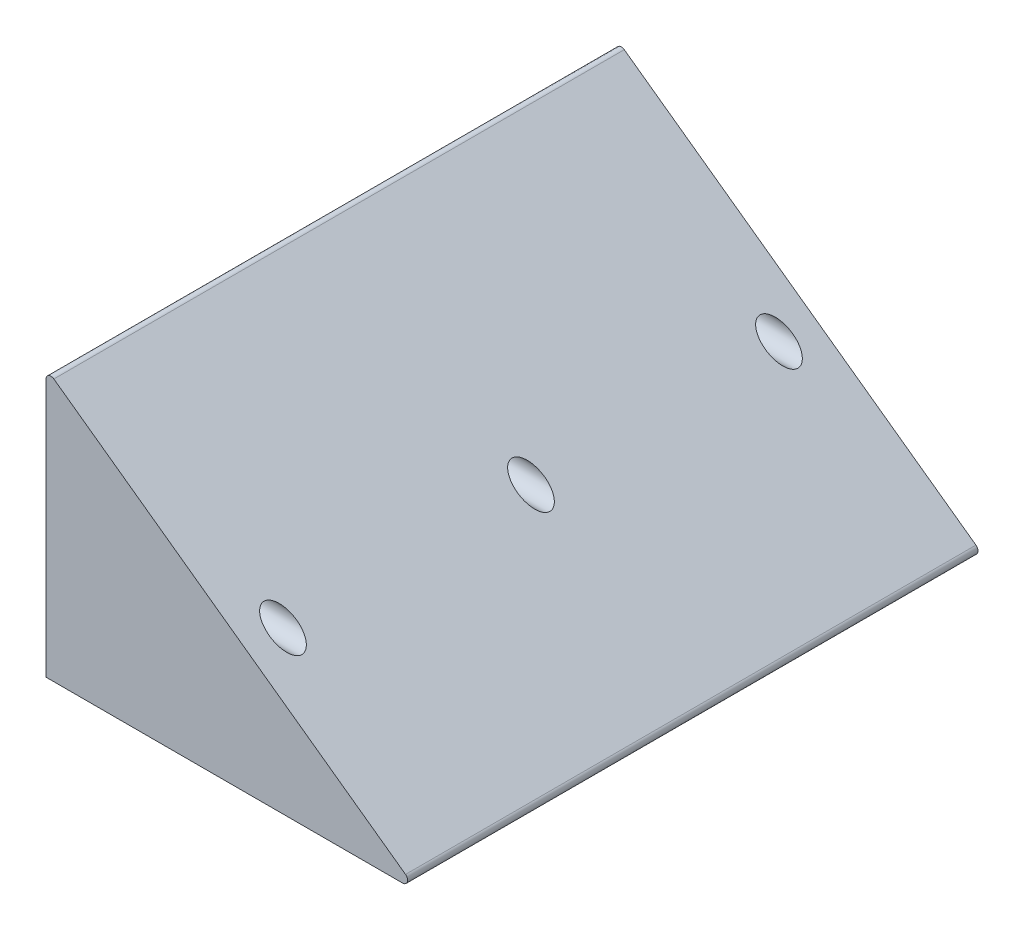
from build123d import *

# Parameters (mm, degrees)
AUFSATZ_LINEAR_AUSTRAGEN1_DEPTH                      = 230
STIRNSENKUNG_F_R_M6_ZYLINDERSCHRAUBE_MIT_D           = 6.6
STIRNSENKUNG_F_R_M6_ZYLINDERSCHRAUBE_MIT_CBORE_D     = 11
STIRNSENKUNG_F_R_M6_ZYLINDERSCHRAUBE_MIT_CBORE_DEPTH = 106.4


with BuildPart() as part:
    # Skizze1 → Aufsatz-Linear austragen1 (new body)
    with BuildSketch(Plane.XY):
        with BuildLine():
            Line((0, 104.095532512), (0, 0))
            Line((0, 0), (143.799350711, 0))
            ThreePointArc((143.799350711, 0), (145.702786731, 1.386052676), (144.967960163, 3.623068683))
            Line((144.967960163, 3.623068683), (3.168609452, 105.718601195))
            ThreePointArc((3.168609452, 105.718601195), (1.088193799, 105.875591346), (0, 104.095532512))
        make_face()
    extrude(amount=-AUFSATZ_LINEAR_AUSTRAGEN1_DEPTH)

    # Stirnsenkung für M6 Zylinderschraube mit Innensechskant1 (through all)
    with Locations(Plane(origin=(150, 0, 0), x_dir=(0, 0, -1), z_dir=(1, 0, 0))):
        with Locations((15, 50), (115, 50), (215, 50)):
            CounterBoreHole(STIRNSENKUNG_F_R_M6_ZYLINDERSCHRAUBE_MIT_D / 2, STIRNSENKUNG_F_R_M6_ZYLINDERSCHRAUBE_MIT_CBORE_D / 2, STIRNSENKUNG_F_R_M6_ZYLINDERSCHRAUBE_MIT_CBORE_DEPTH)


solid = part.part
